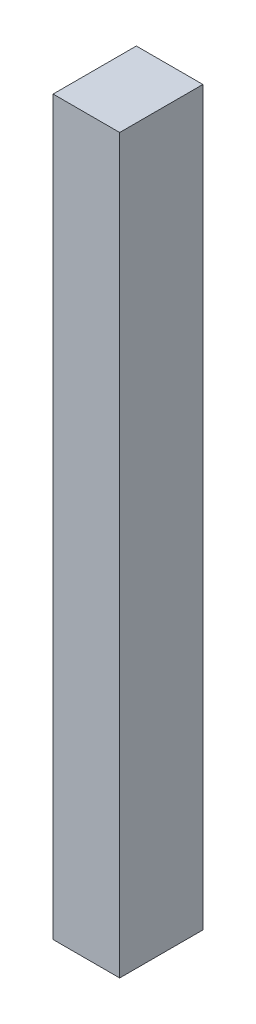
from build123d import *

# Parameters (mm, degrees)
ESQUISSE1_W        = 80
ESQUISSE1_H        = 880
BOSS_EXTRU_1_DEPTH = 100


with BuildPart() as part:
    # Esquisse1 → Boss.-Extru.1 (new body)
    with BuildSketch(Plane.XY):
        Rectangle(ESQUISSE1_W, ESQUISSE1_H)
    extrude(amount=BOSS_EXTRU_1_DEPTH)


solid = part.part
